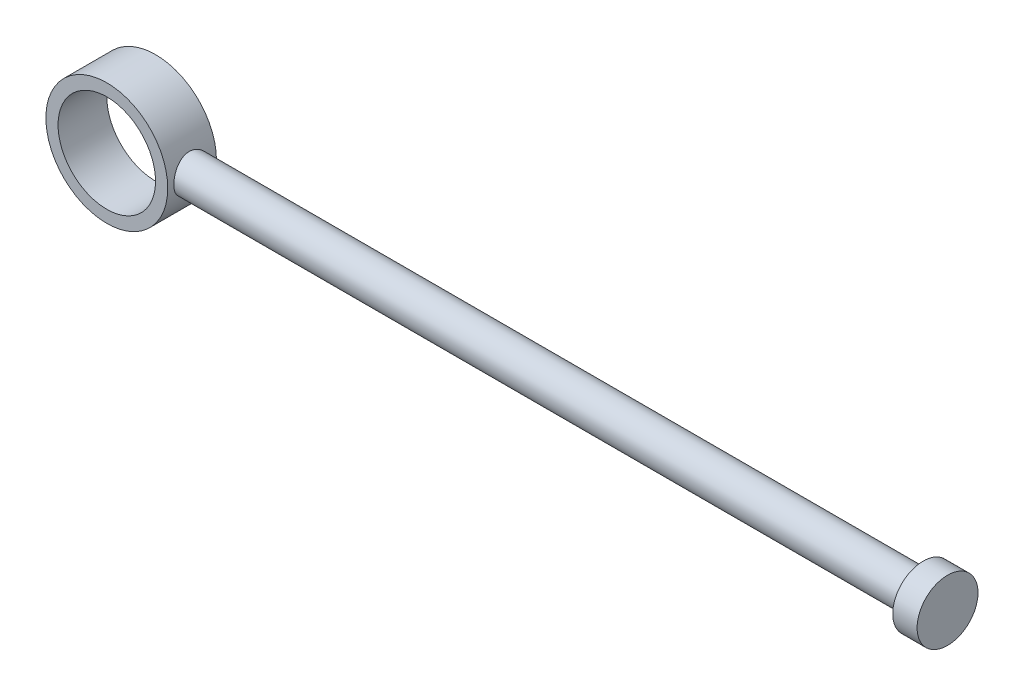
from build123d import *

# Parameters (mm, degrees)
IZIM1_R                                      = 5
IZIM1_R_2                                    = 4
Y_KSEKLIK_EKSTR_ZYON1_DEPTH                  = 4
IZIM2_R                                      = 1.5
Y_KSEKLIK_EKSTR_ZYON2_DEPTH                  = 60
Y_KSEKLIK_EKSTR_ZYON2_DIRECTION_2_REACH      = 13.874
Y_KSEKLIK_EKSTR_ZYON2_DIRECTION_2_END_RADIUS = 5
IZIM3_R                                      = 2.5
Y_KSEKLIK_EKSTR_ZYON3_DEPTH                  = 2


with BuildPart() as part:
    # Çizim1 → Yükseklik-Ekstrüzyon1 (new body)
    with BuildSketch(Plane.XY):
        Circle(IZIM1_R)
        Circle(IZIM1_R_2, mode=Mode.SUBTRACT)
    extrude(amount=Y_KSEKLIK_EKSTR_ZYON1_DEPTH)


with BuildPart() as y_kseklik_ekstr_zyon2_tool:
    # Çizim2 → Yükseklik-Ekstrüzyon2 (new body)
    with BuildSketch(Plane(origin=(5, 0, 0), x_dir=(0, 0, -1), z_dir=(1, 0, 0))):
        with Locations((-2, 0)):
            Circle(IZIM2_R)
    extrude(amount=Y_KSEKLIK_EKSTR_ZYON2_DEPTH)


with BuildPart() as part_1:
    add(part.part)


with BuildPart() as part_2:
    # Yükseklik-Ekstrüzyon2: joined with y_kseklik_ekstr_zyon2_tool
    add(part_1.part.fuse(y_kseklik_ekstr_zyon2_tool.part, tol=0.00001))

    # Yükseklik-Ekstrüzyon2 direction 2: up to this cylinder (the profile starts outside it)
    y_kseklik_ekstr_zyon2_direction_2_end = Plane(origin=(0, 0, 2), z_dir=(0, 0, -1)) * Cylinder(Y_KSEKLIK_EKSTR_ZYON2_DIRECTION_2_END_RADIUS, 38.748, mode=Mode.PRIVATE)
    # Çizim2 → Yükseklik-Ekstrüzyon2 direction 2 (add, up to the surface)
    with BuildSketch(Plane(origin=(5, 0, 0), x_dir=(0, 0, -1), z_dir=(1, 0, 0)), mode=Mode.PRIVATE) as y_kseklik_ekstr_zyon2_direction_2_sk1:
        with Locations((-2, 0)):
            Circle(IZIM2_R)
    y_kseklik_ekstr_zyon2_direction_2_tool1 = extrude(y_kseklik_ekstr_zyon2_direction_2_sk1.sketch, amount=-Y_KSEKLIK_EKSTR_ZYON2_DIRECTION_2_REACH, mode=Mode.PRIVATE) - y_kseklik_ekstr_zyon2_direction_2_end
    add(y_kseklik_ekstr_zyon2_direction_2_tool1.solids().sort_by_distance((5, 0, 2))[0])
    add(y_kseklik_ekstr_zyon2_direction_2_tool1.solids().sort_by_distance((5, 0, 2))[1])

    # Çizim3 → Yükseklik-Ekstrüzyon3 (add)
    with BuildSketch(Plane(origin=(65, 0, 0), x_dir=(0, 0, -1), z_dir=(1, 0, 0))):
        with Locations((-2, 0)):
            Circle(IZIM3_R)
    extrude(amount=Y_KSEKLIK_EKSTR_ZYON3_DEPTH)


solid = part_2.part
